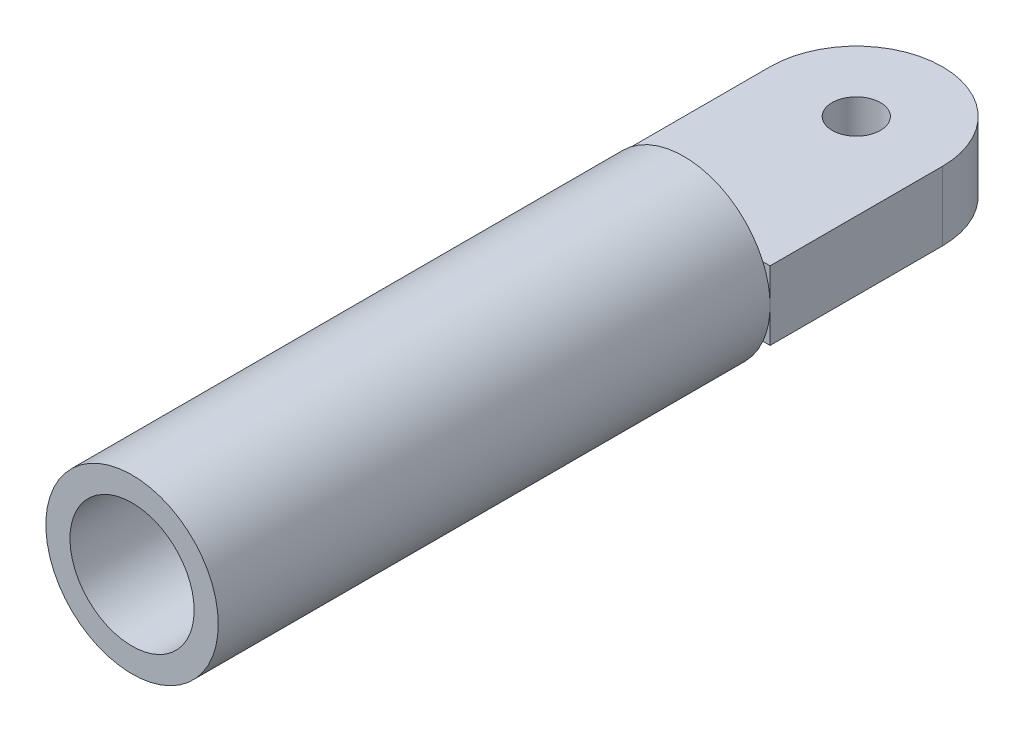
from build123d import *

# Parameters (mm, degrees)
SKETCH1_R           = 12.5
SKETCH1_R_2         = 9
BOSS_EXTRUDE1_DEPTH = 80
SKETCH2_R           = 3.5
BOSS_EXTRUDE2_DEPTH = 5


with BuildPart() as part:
    # Sketch1 → Boss-Extrude1 (new body)
    with BuildSketch(Plane.XY):
        Circle(SKETCH1_R)
        Circle(SKETCH1_R_2, mode=Mode.SUBTRACT)
    extrude(amount=BOSS_EXTRUDE1_DEPTH)

    # Sketch2 → Boss-Extrude2 (add, symmetric)
    with BuildSketch(Plane(origin=(0, 0, 0), x_dir=(1, 0, 0), z_dir=(0, 1, 0))):
        with BuildLine():
            Line((-12.5, 0), (12.5, 0))
            Line((12.5, 0), (12.5, 25))
            ThreePointArc((12.5, 25), (0, 37.5), (-12.5, 25))
            Line((-12.5, 25), (-12.5, 0))
        make_face()
        with Locations((0, 25)):
            Circle(SKETCH2_R, mode=Mode.SUBTRACT)
    extrude(amount=BOSS_EXTRUDE2_DEPTH, both=True)


solid = part.part
